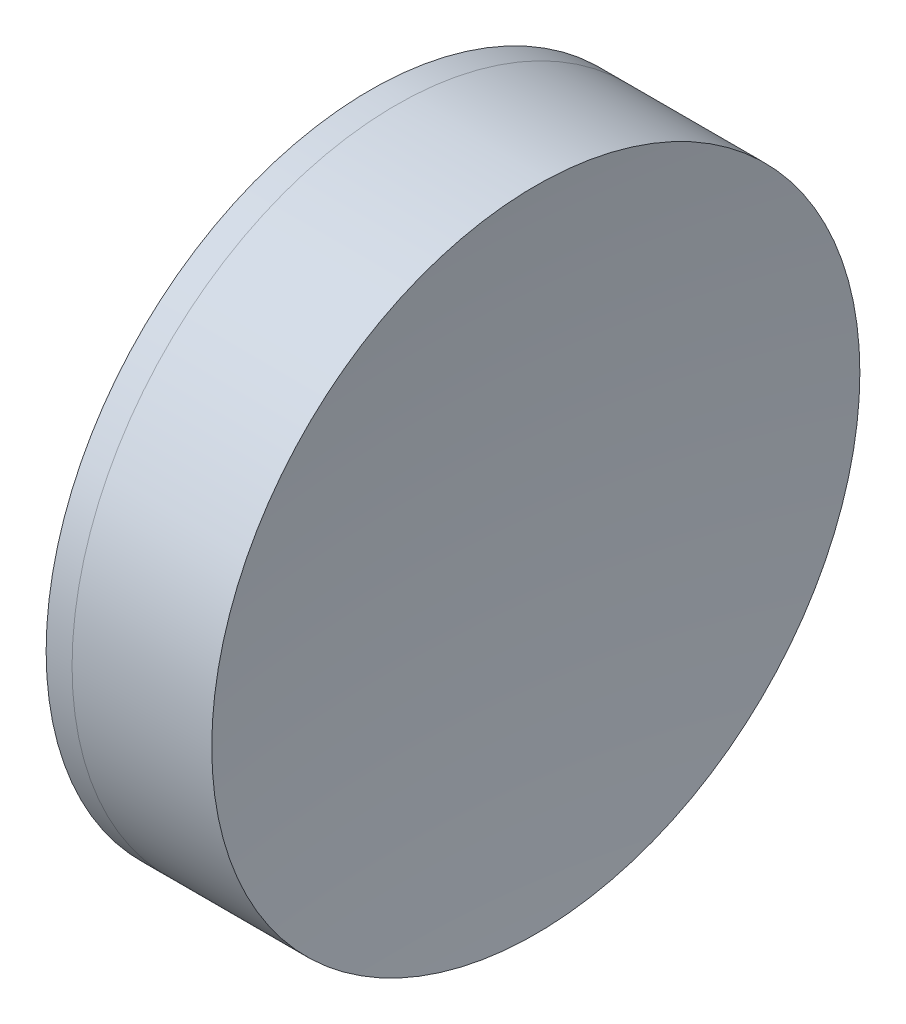
from build123d import *


with BuildPart() as part:
    # 草图1 one side → 旋转1 (revolve)
    with BuildSketch(Plane(origin=(0, 0, 0), x_dir=(1, 0, 0), z_dir=(0, 1, 0)), mode=Mode.PRIVATE) as revolve_1_sk:
        with BuildLine():
            ThreePointArc((50.581563452, 12.7), (48.895160456, 6.449266686), (48.327198098, 0))
            Line((48.327198098, 0), (53.327198098, 0))
            ThreePointArc((53.327198098, 0), (52.892895893, 6.408595094), (51.597931105, 12.7))
            Line((51.597931105, 12.7), (50.581563452, 12.7))
        make_face()
    revolve(revolve_1_sk.sketch.rotate(Axis((-0.816062176, 0, 0), (1, 0, 0)), 180), axis=Axis((-0.816062176, 0, 0), (1, 0, 0)))  # turned: the seam where the file's is


with BuildPart() as body_2:
    # 草图2 one side → 旋转2 (revolve)
    with BuildSketch(Plane(origin=(0, 0, 0), x_dir=(1, 0, 0), z_dir=(0, 1, 0)), mode=Mode.PRIVATE) as revolve_2_sk:
        with BuildLine():
            Line((57.072341925, 12.7), (51.597931105, 12.7))
            ThreePointArc((51.597931105, 12.7), (52.892895893, 6.408595094), (53.327198098, 0))
            Line((53.327198098, 0), (56.327198098, 0))
            ThreePointArc((56.327198098, 0), (56.513644101, 6.360920518), (57.072341925, 12.7))
        make_face()
    revolve(revolve_2_sk.sketch.rotate(Axis((-0.551919993, 0, 0), (1, 0, 0)), 180), axis=Axis((-0.551919993, 0, 0), (1, 0, 0)))  # turned: the seam where the file's is


solid = Compound([part.part, body_2.part])
